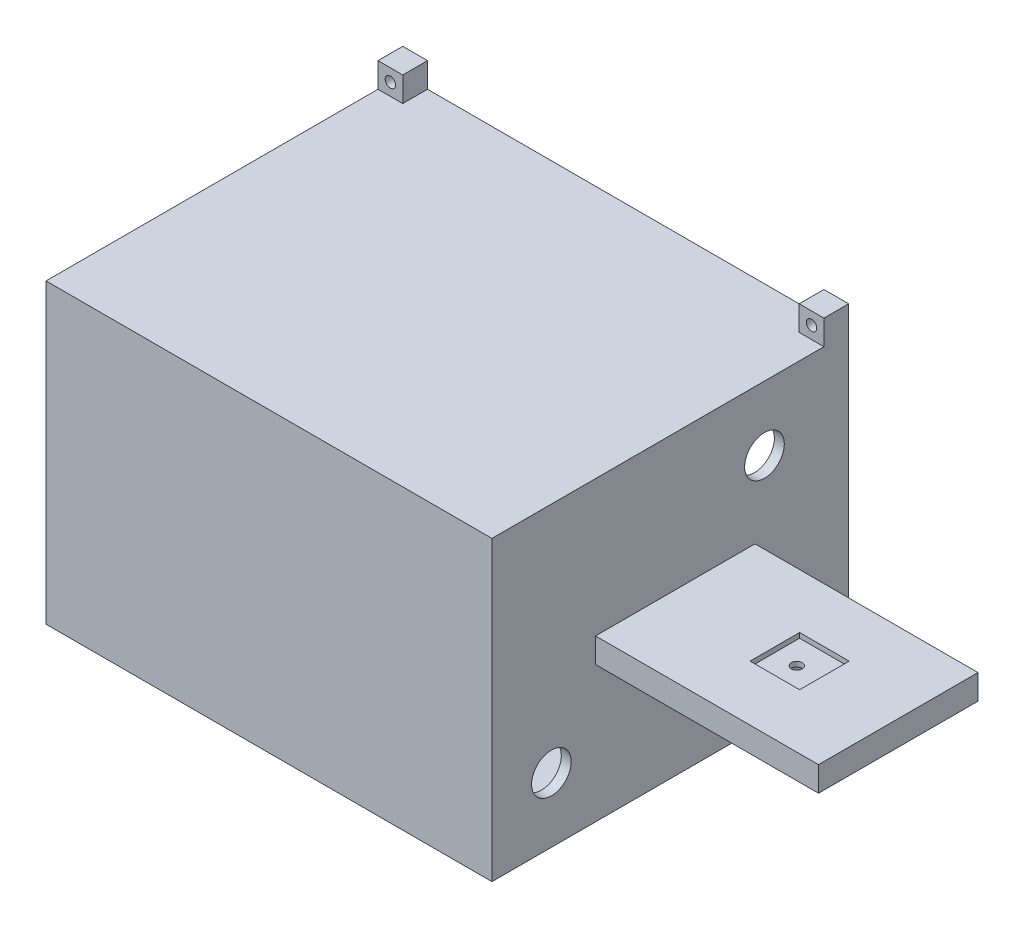
from build123d import *

# Parameters (mm, degrees)
SKETCH_1_W           = 135
SKETCH_1_H           = 60
EXTRUDE_1_DEPTH      = 70
SKETCH_6_W           = 45
SKETCH_6_H           = 70
CUT_EXTRUDE_1_DEPTH  = 27.5
SKETCH_5_W           = 45
SKETCH_5_H           = 70
CUT_EXTRUDE_2_DEPTH  = 27.5
SKETCH_7_W           = 80
SKETCH_7_H           = 50
CUT_EXTRUDE_3_DEPTH  = 75
SKETCH_8_W           = 88
SKETCH_8_H           = 58
SKETCH_8_W_2         = 82
SKETCH_8_H_2         = 52
CUT_EXTRUDE_4_DEPTH  = 6
SKETCH_10_W          = 21.5
SKETCH_10_H          = 15
CUT_EXTRUDE_6_DEPTH  = 10
SKETCH_12_W          = 18.906228009
SKETCH_12_H          = 10
CUT_EXTRUDE_7_DEPTH  = 45
CUT_EXTRUDE_8_DEPTH  = 3
SKETCH_15_W          = 10
SKETCH_15_H          = 10
CUT_EXTRUDE_9_DEPTH  = 1
SKETCH_17_R          = 1.095275866
CUT_EXTRUDE_11_DEPTH = 7
SKETCH_18_W          = 5
SKETCH_18_H          = 5
SKETCH_18_R          = 1.05
EXTRUDE_2_DEPTH      = 5
SKETCH_19_W          = 90
SKETCH_19_H          = 60
EXTRUDE_3_DEPTH      = 2
SKETCH_20_R          = 4
CUT_EXTRUDE_12_DEPTH = 10
SKETCH_21_W          = 86
SKETCH_21_H          = 56
CUT_EXTRUDE_13_DEPTH = 63


with BuildPart() as part:
    # 草圖1 → 填料-伸長1 (new body)
    with BuildSketch(Plane.XY):
        with Locations((-8.008902174, -4.41011236)):
            Rectangle(SKETCH_1_W, SKETCH_1_H)
    extrude(amount=EXTRUDE_1_DEPTH)

    # 草圖6 → 除料-伸長1 (cut)
    with BuildSketch(Plane(origin=(0, 25.58988764, 0), x_dir=(1, 0, 0), z_dir=(0, 1, 0))):
        with Locations((36.991097826, -35)):
            Rectangle(SKETCH_6_W, SKETCH_6_H)
    extrude(amount=-CUT_EXTRUDE_1_DEPTH, mode=Mode.SUBTRACT)

    # 草圖5 → 除料-伸長2 (cut)
    with BuildSketch(Plane.XZ.offset(34.41011236)):
        with Locations((36.991097826, 35)):
            Rectangle(SKETCH_5_W, SKETCH_5_H)
    extrude(amount=-CUT_EXTRUDE_2_DEPTH, mode=Mode.SUBTRACT)

    # 草圖7 → 除料-伸長3 (cut)
    with BuildSketch(Plane.XY):
        with Locations((-30.508902174, -4.41011236)):
            Rectangle(SKETCH_7_W, SKETCH_7_H)
    extrude(amount=CUT_EXTRUDE_3_DEPTH, mode=Mode.SUBTRACT)

    # 草圖8 → 除料-伸長4 (cut)
    with BuildSketch(Plane(origin=(0, 0, 0), x_dir=(-1, 0, 0), z_dir=(0, 0, -1))):
        with Locations((30.508902174, -4.41011236)):
            Rectangle(SKETCH_8_W, SKETCH_8_H)
        with Locations((30.508902174, -4.41011236)):
            Rectangle(SKETCH_8_W_2, SKETCH_8_H_2, mode=Mode.SUBTRACT)
    extrude(amount=-CUT_EXTRUDE_4_DEPTH, mode=Mode.SUBTRACT)

    # 草圖10 → 除料-伸長6 (cut)
    with BuildSketch(Plane(origin=(0, -34.41011236, 0), x_dir=(-1, 0, 0), z_dir=(0, -1, 0))):
        with Locations((24.758902174, -19.5)):
            Rectangle(SKETCH_10_W, SKETCH_10_H)
    extrude(amount=-CUT_EXTRUDE_6_DEPTH, mode=Mode.SUBTRACT)

    # 草圖12 → 除料-伸長7 (cut)
    with BuildSketch(Plane(origin=(14.491097826, 0, 0), x_dir=(0, 0, -1), z_dir=(1, 0, 0))):
        with Locations((-60.546885996, -4.41011236)):
            Rectangle(SKETCH_12_W, SKETCH_12_H)
        with Locations((-9.453114004, -4.41011236)):
            Rectangle(SKETCH_12_W, SKETCH_12_H)
    extrude(amount=CUT_EXTRUDE_7_DEPTH, mode=Mode.SUBTRACT)

    # 草圖14 → 除料-伸長8 (cut)
    with BuildSketch(Plane(origin=(0, -6.91011236, 0), x_dir=(-1, 0, 0), z_dir=(0, -1, 0))):
        with BuildLine():
            Line((-38.126130034, -30.080170747), (-22.017914827, -33))
            ThreePointArc((-22.017914827, -33), (-20.017914827, -35), (-22.017914827, -37))
            Line((-22.017914827, -37), (-38.126130034, -39.919829253))
            ThreePointArc((-38.126130034, -39.919829253), (-39.017914827, -40), (-39.909699621, -39.919829253))
            Line((-39.909699621, -39.919829253), (-56.017914827, -37))
            ThreePointArc((-56.017914827, -37), (-58.017914827, -35), (-56.017914827, -33))
            Line((-56.017914827, -33), (-39.909699621, -30.080170747))
            ThreePointArc((-39.909699621, -30.080170747), (-39.017914827, -30), (-38.126130034, -30.080170747))
        make_face()
    extrude(amount=-CUT_EXTRUDE_8_DEPTH, mode=Mode.SUBTRACT)

    # 草圖15 → 除料-伸長9 (cut)
    with BuildSketch(Plane(origin=(0, -1.91011236, 0), x_dir=(1, 0, 0), z_dir=(0, 1, 0))):
        with Locations((39.491097826, -34.906228009)):
            Rectangle(SKETCH_15_W, SKETCH_15_H)
    extrude(amount=-CUT_EXTRUDE_9_DEPTH, mode=Mode.SUBTRACT)

    # 草圖17 → 除料-伸長11 (cut)
    with BuildSketch(Plane(origin=(0, -6.91011236, 0), x_dir=(-1, 0, 0), z_dir=(0, -1, 0))):
        with Locations((-39.017914827, -35)):
            Circle(SKETCH_17_R)
    extrude(amount=-CUT_EXTRUDE_11_DEPTH, mode=Mode.SUBTRACT)

    # 草圖18 → 填料-伸長2 (add)
    with BuildSketch(Plane.XY):
        with Locations((11.991097826, 28.08988764)):
            Rectangle(SKETCH_18_W, SKETCH_18_H)
        with Locations((11.991097826, 28.08988764)):
            Circle(SKETCH_18_R, mode=Mode.SUBTRACT)
        with Locations((-73.008902174, 28.08988764)):
            Rectangle(SKETCH_18_W, SKETCH_18_H)
        with Locations((-73.008902174, 28.08988764)):
            Circle(SKETCH_18_R, mode=Mode.SUBTRACT)
        with Locations((-73.008902174, -36.91011236)):
            Rectangle(SKETCH_18_W, SKETCH_18_H)
        with Locations((-73.008902174, -36.91011236)):
            Circle(SKETCH_18_R, mode=Mode.SUBTRACT)
        with Locations((11.991097826, -36.91011236)):
            Rectangle(SKETCH_18_W, SKETCH_18_H)
        with Locations((11.991097826, -36.91011236)):
            Circle(SKETCH_18_R, mode=Mode.SUBTRACT)
    extrude(amount=EXTRUDE_2_DEPTH)

    # 草圖19 → 填料-伸長3 (add)
    with BuildSketch(Plane.XY.offset(70)):
        with Locations((-30.508902174, -4.41011236)):
            Rectangle(SKETCH_19_W, SKETCH_19_H)
    extrude(amount=EXTRUDE_3_DEPTH)

    # 草圖20 → 除料-伸長12 (cut)
    with BuildSketch(Plane(origin=(14.491097826, 0, 0), x_dir=(0, 0, -1), z_dir=(1, 0, 0))):
        with Locations((-60, -21.41011236)):
            Circle(SKETCH_20_R)
        with Locations((-17, 12.58988764)):
            Circle(SKETCH_20_R)
    extrude(amount=-CUT_EXTRUDE_12_DEPTH, mode=Mode.SUBTRACT)

    # 草圖21 → 除料-伸長13 (cut)
    with BuildSketch(Plane(origin=(0, 0, 7), x_dir=(-1, 0, 0), z_dir=(0, 0, -1))):
        with Locations((30.508902174, -4.41011236)):
            Rectangle(SKETCH_21_W, SKETCH_21_H)
    extrude(amount=-CUT_EXTRUDE_13_DEPTH, mode=Mode.SUBTRACT)


solid = part.part
